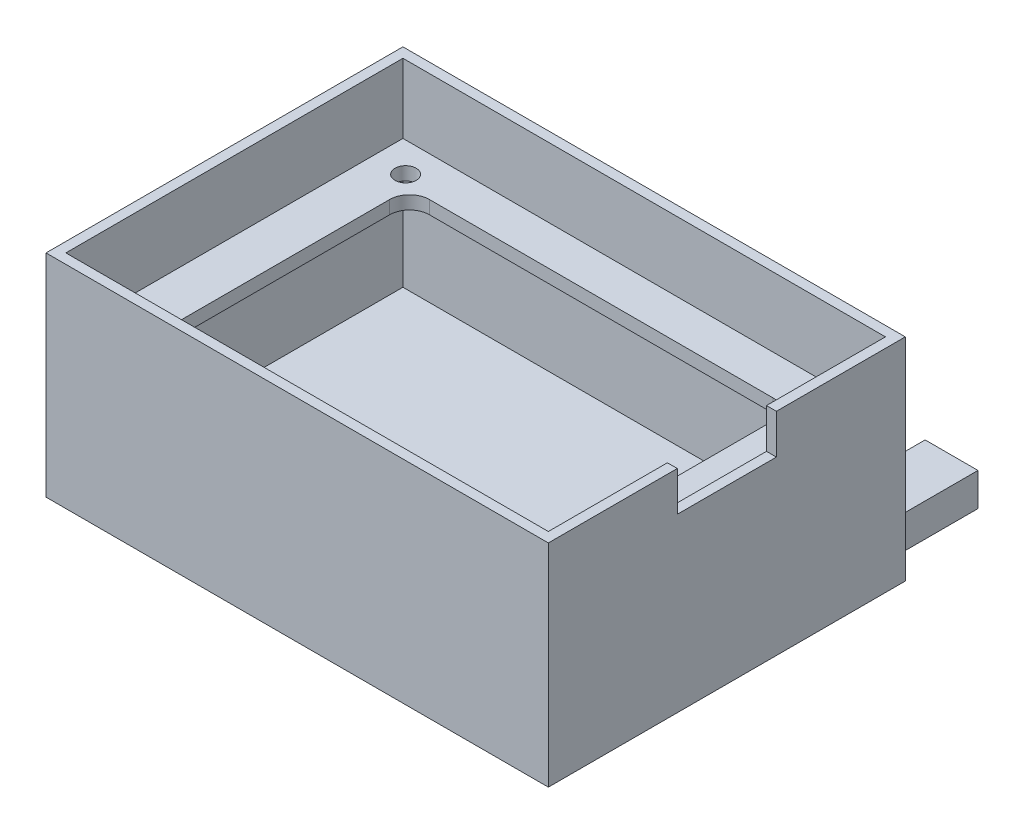
from build123d import *

# Parameters (mm, degrees)
ENCLOSURE_SHELL_SKETCH_W      = 76
ENCLOSURE_SHELL_SKETCH_H      = 54
ENCLOSURE_SHELL_FEATURE_DEPTH = 32
ENCLOSURE_GAP_SKETCH_W        = 73
ENCLOSURE_GAP_SKETCH_H        = 51
ENCLOSURE_GAP_FEATURE_DEPTH   = 30
SCREW_SHELL_SKETCH_R          = 2.5
SCREW_SHELL_FEATURE_DEPTH     = 8
BATTERY_CUT_REACH             = 78
BATTERY_CUT_DIRECTION_2_DEPTH = 1
CAMERA_CORD_HOLE_SKETCH_W     = 20
CAMERA_CORD_HOLE_SKETCH_H     = 12
CAMERA_CORD_HOLE_DEPTH        = 3
TAB_FEATURE_SKETCH_W          = 8
TAB_FEATURE_SKETCH_H          = 5
TAB_FEATURE_DEPTH             = 15
BOSS_EXTRUDE2_START           = -2
SKETCH1_W                     = 72
SKETCH1_H                     = 50
BOSS_EXTRUDE2_DEPTH           = 20
CUT_EXTRUDE1_START            = -2
SKETCH2_W                     = 72
SKETCH2_H                     = 50
CUT_EXTRUDE1_DEPTH            = 18
SKETCH4_W                     = 58
SKETCH4_H                     = 38
CUT_EXTRUDE3_DEPTH            = 2
SKETCH5_R                     = 1.6
CUT_EXTRUDE4_DEPTH            = 10
FILLET1_R                     = 3
FILLET3_R                     = 3
FILLET4_R                     = 3
FILLET5_R                     = 3


with BuildPart() as part:
    # Enclosure Shell Sketch → Enclosure Shell Feature (new body)
    with BuildSketch(Plane(origin=(0, 0, 0), x_dir=(1, 0, 0), z_dir=(0, 1, 0))):
        Rectangle(ENCLOSURE_SHELL_SKETCH_W, ENCLOSURE_SHELL_SKETCH_H)
    extrude(amount=ENCLOSURE_SHELL_FEATURE_DEPTH)

    # Enclosure Gap Sketch → Enclosure Gap Feature (cut)
    with BuildSketch(Plane(origin=(0, 32, 0), x_dir=(1, 0, 0), z_dir=(0, 1, 0))):
        Rectangle(ENCLOSURE_GAP_SKETCH_W, ENCLOSURE_GAP_SKETCH_H)
    extrude(amount=-ENCLOSURE_GAP_FEATURE_DEPTH, mode=Mode.SUBTRACT)

    # Screw Shell Sketch → Screw Shell Feature (add)
    with BuildSketch(Plane(origin=(0, 2, 0), x_dir=(1, 0, 0), z_dir=(0, 1, 0))):
        with Locations((-31.088465065, 20.5)):
            Circle(SCREW_SHELL_SKETCH_R)
        with Locations((-31.1, -20.5)):
            Circle(SCREW_SHELL_SKETCH_R)
        with Locations((31.1, 20.5)):
            Circle(SCREW_SHELL_SKETCH_R)
        with Locations((31.1, -20.5)):
            Circle(SCREW_SHELL_SKETCH_R)
    extrude(amount=SCREW_SHELL_FEATURE_DEPTH)

    # Battery Cut Sketch → Battery Cut (cut, up to next)
    with BuildSketch(Plane.ZY.offset(-38), mode=Mode.PRIVATE) as battery_cut_sk1:
        Polygon((0, 32), (7.492527579, 32), (7.492527579, 26), (-7.5, 26), (-7.5, 32), align=None)
    battery_cut_tool1 = extrude(battery_cut_sk1.sketch, amount=BATTERY_CUT_REACH, mode=Mode.PRIVATE) & part.part
    add(battery_cut_tool1.solids().sort_by_distance((38, 29, -0.003736))[0], mode=Mode.SUBTRACT)

    # Battery Cut Sketch → Battery Cut direction 2 (cut)
    with BuildSketch(Plane.ZY.offset(-38)):
        Polygon((0, 32), (7.492527579, 32), (7.492527579, 26), (-7.5, 26), (-7.5, 32), align=None)
    extrude(amount=-BATTERY_CUT_DIRECTION_2_DEPTH, mode=Mode.SUBTRACT)

    # Camera Cord Hole Sketch → Camera Cord Hole (cut, through all)
    with BuildSketch(Plane(origin=(0, 2, 0), x_dir=(1, 0, 0), z_dir=(0, 1, 0))):
        with Locations((-17.5, -9.5)):
            Rectangle(CAMERA_CORD_HOLE_SKETCH_W, CAMERA_CORD_HOLE_SKETCH_H)
    extrude(amount=-CAMERA_CORD_HOLE_DEPTH, mode=Mode.SUBTRACT)

    # Tab Feature Sketch → Tab Feature (add)
    with BuildSketch(Plane(origin=(0, 0, -27), x_dir=(-1, 0, 0), z_dir=(0, 0, -1))):
        with Locations((-30, 2.5)):
            Rectangle(TAB_FEATURE_SKETCH_W, TAB_FEATURE_SKETCH_H)
        with Locations((30, 2.5)):
            Rectangle(TAB_FEATURE_SKETCH_W, TAB_FEATURE_SKETCH_H)
    extrude(amount=TAB_FEATURE_DEPTH)

    # Sketch1 → Boss-Extrude2 (add)
    with BuildSketch(Plane(origin=(0, 0, 0), x_dir=(-1, 0, 0), z_dir=(0, -1, 0)).offset(BOSS_EXTRUDE2_START)):
        Rectangle(SKETCH1_W, SKETCH1_H)
    extrude(amount=-BOSS_EXTRUDE2_DEPTH)

    # Sketch2 → Cut-Extrude1 (cut)
    with BuildSketch(Plane(origin=(0, 0, 0), x_dir=(-1, 0, 0), z_dir=(0, -1, 0)).offset(CUT_EXTRUDE1_START)):
        Rectangle(SKETCH2_W, SKETCH2_H)
    extrude(amount=-CUT_EXTRUDE1_DEPTH, mode=Mode.SUBTRACT)

    # Sketch4 → Cut-Extrude3 (cut)
    with BuildSketch(Plane(origin=(0, 22, 0), x_dir=(1, 0, 0), z_dir=(0, 1, 0))):
        Rectangle(SKETCH4_W, SKETCH4_H)
    extrude(amount=-CUT_EXTRUDE3_DEPTH, mode=Mode.SUBTRACT)

    # Sketch5 → Cut-Extrude4 (cut)
    with BuildSketch(Plane(origin=(0, 22, 0), x_dir=(1, 0, 0), z_dir=(0, 1, 0))):
        with Locations((-31.1, 20.5)):
            Circle(SKETCH5_R)
        with Locations((31.1, 20.5)):
            Circle(SKETCH5_R)
        with Locations((31.1, -20.5)):
            Circle(SKETCH5_R)
        with Locations((-31.1, -20.5)):
            Circle(SKETCH5_R)
    extrude(amount=-CUT_EXTRUDE4_DEPTH, mode=Mode.SUBTRACT)

    # Fillet1
    fillet1_edges = [part.edges().sort_by_distance(p)[0] for p in [
        (-29, 21, -19),
    ]]
    fillet(fillet1_edges, radius=FILLET1_R)

    # Fillet3
    fillet3_edges = [part.edges().sort_by_distance(p)[0] for p in [
        (29, 21, -19),
    ]]
    fillet(fillet3_edges, radius=FILLET3_R)

    # Fillet4
    fillet4_edges = [part.edges().sort_by_distance(p)[0] for p in [
        (29, 21, 19),
    ]]
    fillet(fillet4_edges, radius=FILLET4_R)

    # Fillet5
    fillet5_edges = [part.edges().sort_by_distance(p)[0] for p in [
        (-29, 21, 19),
    ]]
    fillet(fillet5_edges, radius=FILLET5_R)


solid = part.part
